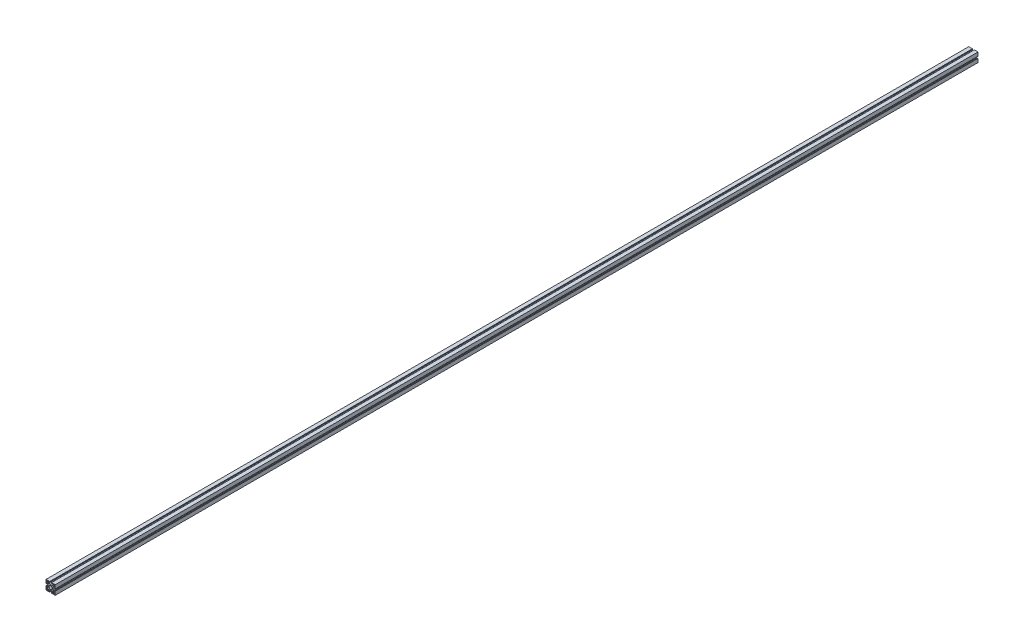
from build123d import *

# Parameters (mm, degrees)
CROQUIS1_R              = 6.85
SALIENTE_EXTRUIR1_DEPTH = 4000


with BuildPart() as part:
    # Croquis1 → Saliente-Extruir1 (new body)
    with BuildSketch(Plane.XY):
        with BuildLine():
            Line((-20, -20), (-4.095, -20))
            Line((-4.095, -20), (-4.095, -19.49))
            ThreePointArc((-4.095, -19.49), (-4.182867966, -19.277867966), (-4.395, -19.19))
            Line((-4.395, -19.19), (-4.730448424, -19.19))
            Line((-4.730448424, -19.19), (-4.730448424, -18.19))
            Line((-4.730448424, -18.19), (-4.395, -18.19))
            ThreePointArc((-4.395, -18.19), (-4.182867966, -18.102132034), (-4.095, -17.89))
            Line((-4.095, -17.89), (-4.095, -16.49))
            ThreePointArc((-4.095, -16.49), (-4.182867966, -16.277867966), (-4.395, -16.19))
            Line((-4.395, -16.19), (-6.206379539, -16.19))
            ThreePointArc((-6.206379539, -16.19), (-6.55993293, -16.336446609), (-6.706379539, -16.69))
            Line((-6.706379539, -16.69), (-6.706379539, -18.19))
            Line((-6.706379539, -18.19), (-10.5, -18.19))
            ThreePointArc((-10.5, -18.19), (-10.853553391, -18.043553391), (-11, -17.69))
            Line((-11, -17.69), (-11, -15))
            ThreePointArc((-11, -15), (-9.828427125, -12.171572875), (-7, -11))
            Line((-7, -11), (7, -11))
            ThreePointArc((7, -11), (9.828427125, -12.171572875), (11, -15))
            Line((11, -15), (11, -17.69))
            ThreePointArc((11, -17.69), (10.853553391, -18.043553391), (10.5, -18.19))
            Line((10.5, -18.19), (6.706379539, -18.19))
            Line((6.706379539, -18.19), (6.706379539, -16.69))
            ThreePointArc((6.706379539, -16.69), (6.55993293, -16.336446609), (6.206379539, -16.19))
            Line((6.206379539, -16.19), (4.395, -16.19))
            ThreePointArc((4.395, -16.19), (4.182867966, -16.277867966), (4.095, -16.49))
            Line((4.095, -16.49), (4.095, -17.89))
            ThreePointArc((4.095, -17.89), (4.182867966, -18.102132034), (4.395, -18.19))
            Line((4.395, -18.19), (4.730448424, -18.19))
            Line((4.730448424, -18.19), (4.730448424, -19.19))
            Line((4.730448424, -19.19), (4.395, -19.19))
            ThreePointArc((4.395, -19.19), (4.182867966, -19.277867966), (4.095, -19.49))
            Line((4.095, -19.49), (4.095, -20))
            Line((4.095, -20), (20, -20))
            Line((20, -20), (20, -4.095))
            Line((20, -4.095), (19.49, -4.095))
            ThreePointArc((19.49, -4.095), (19.277867966, -4.182867966), (19.19, -4.395))
            Line((19.19, -4.395), (19.19, -4.730448424))
            Line((19.19, -4.730448424), (18.19, -4.730448424))
            Line((18.19, -4.730448424), (18.19, -4.395))
            ThreePointArc((18.19, -4.395), (18.102132034, -4.182867966), (17.89, -4.095))
            Line((17.89, -4.095), (16.49, -4.095))
            ThreePointArc((16.49, -4.095), (16.277867966, -4.182867966), (16.19, -4.395))
            Line((16.19, -4.395), (16.19, -6.206379539))
            ThreePointArc((16.19, -6.206379539), (16.336446609, -6.55993293), (16.69, -6.706379539))
            Line((16.69, -6.706379539), (18.19, -6.706379539))
            Line((18.19, -6.706379539), (18.19, -10.5))
            ThreePointArc((18.19, -10.5), (18.043553391, -10.853553391), (17.69, -11))
            Line((17.69, -11), (15, -11))
            ThreePointArc((15, -11), (12.171572875, -9.828427125), (11, -7))
            Line((11, -7), (11, 7))
            ThreePointArc((11, 7), (12.171572875, 9.828427125), (15, 11))
            Line((15, 11), (17.69, 11))
            ThreePointArc((17.69, 11), (18.043553391, 10.853553391), (18.19, 10.5))
            Line((18.19, 10.5), (18.19, 6.706379539))
            Line((18.19, 6.706379539), (16.69, 6.706379539))
            ThreePointArc((16.69, 6.706379539), (16.336446609, 6.55993293), (16.19, 6.206379539))
            Line((16.19, 6.206379539), (16.19, 4.395))
            ThreePointArc((16.19, 4.395), (16.277867966, 4.182867966), (16.49, 4.095))
            Line((16.49, 4.095), (17.89, 4.095))
            ThreePointArc((17.89, 4.095), (18.102132034, 4.182867966), (18.19, 4.395))
            Line((18.19, 4.395), (18.19, 4.730448424))
            Line((18.19, 4.730448424), (19.19, 4.730448424))
            Line((19.19, 4.730448424), (19.19, 4.395))
            ThreePointArc((19.19, 4.395), (19.277867966, 4.182867966), (19.49, 4.095))
            Line((19.49, 4.095), (20, 4.095))
            Line((20, 4.095), (20, 20))
            Line((20, 20), (4.095, 20))
            Line((4.095, 20), (4.095, 19.49))
            ThreePointArc((4.095, 19.49), (4.182867966, 19.277867966), (4.395, 19.19))
            Line((4.395, 19.19), (4.730448424, 19.19))
            Line((4.730448424, 19.19), (4.730448424, 18.19))
            Line((4.730448424, 18.19), (4.395, 18.19))
            ThreePointArc((4.395, 18.19), (4.182867966, 18.102132034), (4.095, 17.89))
            Line((4.095, 17.89), (4.095, 16.49))
            ThreePointArc((4.095, 16.49), (4.182867966, 16.277867966), (4.395, 16.19))
            Line((4.395, 16.19), (6.206379539, 16.19))
            ThreePointArc((6.206379539, 16.19), (6.55993293, 16.336446609), (6.706379539, 16.69))
            Line((6.706379539, 16.69), (6.706379539, 18.19))
            Line((6.706379539, 18.19), (10.5, 18.19))
            ThreePointArc((10.5, 18.19), (10.853553391, 18.043553391), (11, 17.69))
            Line((11, 17.69), (11, 15))
            ThreePointArc((11, 15), (9.828427125, 12.171572875), (7, 11))
            Line((7, 11), (-7, 11))
            ThreePointArc((-7, 11), (-9.828427125, 12.171572875), (-11, 15))
            Line((-11, 15), (-11, 17.69))
            ThreePointArc((-11, 17.69), (-10.853553391, 18.043553391), (-10.5, 18.19))
            Line((-10.5, 18.19), (-6.706379539, 18.19))
            Line((-6.706379539, 18.19), (-6.706379539, 16.69))
            ThreePointArc((-6.706379539, 16.69), (-6.55993293, 16.336446609), (-6.206379539, 16.19))
            Line((-6.206379539, 16.19), (-4.395, 16.19))
            ThreePointArc((-4.395, 16.19), (-4.182867966, 16.277867966), (-4.095, 16.49))
            Line((-4.095, 16.49), (-4.095, 17.89))
            ThreePointArc((-4.095, 17.89), (-4.182867966, 18.102132034), (-4.395, 18.19))
            Line((-4.395, 18.19), (-4.730448424, 18.19))
            Line((-4.730448424, 18.19), (-4.730448424, 19.19))
            Line((-4.730448424, 19.19), (-4.395, 19.19))
            ThreePointArc((-4.395, 19.19), (-4.182867966, 19.277867966), (-4.095, 19.49))
            Line((-4.095, 19.49), (-4.095, 20))
            Line((-4.095, 20), (-20, 20))
            Line((-20, 20), (-20, 4.095))
            Line((-20, 4.095), (-19.49, 4.095))
            ThreePointArc((-19.49, 4.095), (-19.277867966, 4.182867966), (-19.19, 4.395))
            Line((-19.19, 4.395), (-19.19, 4.730448424))
            Line((-19.19, 4.730448424), (-18.19, 4.730448424))
            Line((-18.19, 4.730448424), (-18.19, 4.395))
            ThreePointArc((-18.19, 4.395), (-18.102132034, 4.182867966), (-17.89, 4.095))
            Line((-17.89, 4.095), (-16.49, 4.095))
            ThreePointArc((-16.49, 4.095), (-16.277867966, 4.182867966), (-16.19, 4.395))
            Line((-16.19, 4.395), (-16.19, 6.206379539))
            ThreePointArc((-16.19, 6.206379539), (-16.336446609, 6.55993293), (-16.69, 6.706379539))
            Line((-16.69, 6.706379539), (-18.19, 6.706379539))
            Line((-18.19, 6.706379539), (-18.19, 10.5))
            ThreePointArc((-18.19, 10.5), (-18.043553391, 10.853553391), (-17.69, 11))
            Line((-17.69, 11), (-15, 11))
            ThreePointArc((-15, 11), (-12.171572875, 9.828427125), (-11, 7))
            Line((-11, 7), (-11, -7))
            ThreePointArc((-11, -7), (-12.171572875, -9.828427125), (-15, -11))
            Line((-15, -11), (-17.69, -11))
            ThreePointArc((-17.69, -11), (-18.043553391, -10.853553391), (-18.19, -10.5))
            Line((-18.19, -10.5), (-18.19, -6.706379539))
            Line((-18.19, -6.706379539), (-16.69, -6.706379539))
            ThreePointArc((-16.69, -6.706379539), (-16.336446609, -6.55993293), (-16.19, -6.206379539))
            Line((-16.19, -6.206379539), (-16.19, -4.395))
            ThreePointArc((-16.19, -4.395), (-16.277867966, -4.182867966), (-16.49, -4.095))
            Line((-16.49, -4.095), (-17.89, -4.095))
            ThreePointArc((-17.89, -4.095), (-18.102132034, -4.182867966), (-18.19, -4.395))
            Line((-18.19, -4.395), (-18.19, -4.730448424))
            Line((-18.19, -4.730448424), (-19.19, -4.730448424))
            Line((-19.19, -4.730448424), (-19.19, -4.395))
            ThreePointArc((-19.19, -4.395), (-19.277867966, -4.182867966), (-19.49, -4.095))
            Line((-19.49, -4.095), (-20, -4.095))
            Line((-20, -4.095), (-20, -20))
        make_face()
        Circle(CROQUIS1_R, mode=Mode.SUBTRACT)
        with BuildLine():
            Line((-14.109034097, -13.422690717), (-13.737612474, -13.051269094))
            Line((-13.737612474, -13.051269094), (-13.051269094, -13.737612474))
            Line((-13.051269094, -13.737612474), (-13.422690717, -14.109034097))
            ThreePointArc((-13.422690717, -14.109034097), (-13, -15.5), (-13.422690717, -16.890965903))
            Line((-13.422690717, -16.890965903), (-13.051269094, -17.262387526))
            Line((-13.051269094, -17.262387526), (-13.737612474, -17.948730906))
            Line((-13.737612474, -17.948730906), (-14.109034097, -17.577309283))
            ThreePointArc((-14.109034097, -17.577309283), (-15.5, -18), (-16.890965903, -17.577309283))
            Line((-16.890965903, -17.577309283), (-17.262387526, -17.948730906))
            Line((-17.262387526, -17.948730906), (-17.948730906, -17.262387526))
            Line((-17.948730906, -17.262387526), (-17.577309283, -16.890965903))
            ThreePointArc((-17.577309283, -16.890965903), (-18, -15.5), (-17.577309283, -14.109034097))
            Line((-17.577309283, -14.109034097), (-17.948730906, -13.737612474))
            Line((-17.948730906, -13.737612474), (-17.262387526, -13.051269094))
            Line((-17.262387526, -13.051269094), (-16.890965903, -13.422690717))
            ThreePointArc((-16.890965903, -13.422690717), (-15.5, -13), (-14.109034097, -13.422690717))
        make_face(mode=Mode.SUBTRACT)
        with BuildLine():
            Line((-14.109034097, 13.422690717), (-13.737612474, 13.051269094))
            Line((-13.737612474, 13.051269094), (-13.051269094, 13.737612474))
            Line((-13.051269094, 13.737612474), (-13.422690717, 14.109034097))
            ThreePointArc((-13.422690717, 14.109034097), (-13, 15.5), (-13.422690717, 16.890965903))
            Line((-13.422690717, 16.890965903), (-13.051269094, 17.262387526))
            Line((-13.051269094, 17.262387526), (-13.737612474, 17.948730906))
            Line((-13.737612474, 17.948730906), (-14.109034097, 17.577309283))
            ThreePointArc((-14.109034097, 17.577309283), (-15.5, 18), (-16.890965903, 17.577309283))
            Line((-16.890965903, 17.577309283), (-17.262387526, 17.948730906))
            Line((-17.262387526, 17.948730906), (-17.948730906, 17.262387526))
            Line((-17.948730906, 17.262387526), (-17.577309283, 16.890965903))
            ThreePointArc((-17.577309283, 16.890965903), (-18, 15.5), (-17.577309283, 14.109034097))
            Line((-17.577309283, 14.109034097), (-17.948730906, 13.737612474))
            Line((-17.948730906, 13.737612474), (-17.262387526, 13.051269094))
            Line((-17.262387526, 13.051269094), (-16.890965903, 13.422690717))
            ThreePointArc((-16.890965903, 13.422690717), (-15.5, 13), (-14.109034097, 13.422690717))
        make_face(mode=Mode.SUBTRACT)
        with BuildLine():
            Line((13.422690717, 14.109034097), (13.051269094, 13.737612474))
            Line((13.051269094, 13.737612474), (13.737612474, 13.051269094))
            Line((13.737612474, 13.051269094), (14.109034097, 13.422690717))
            ThreePointArc((14.109034097, 13.422690717), (15.5, 13), (16.890965903, 13.422690717))
            Line((16.890965903, 13.422690717), (17.262387526, 13.051269094))
            Line((17.262387526, 13.051269094), (17.948730906, 13.737612474))
            Line((17.948730906, 13.737612474), (17.577309283, 14.109034097))
            ThreePointArc((17.577309283, 14.109034097), (18, 15.5), (17.577309283, 16.890965903))
            Line((17.577309283, 16.890965903), (17.948730906, 17.262387526))
            Line((17.948730906, 17.262387526), (17.262387526, 17.948730906))
            Line((17.262387526, 17.948730906), (16.890965903, 17.577309283))
            ThreePointArc((16.890965903, 17.577309283), (15.5, 18), (14.109034097, 17.577309283))
            Line((14.109034097, 17.577309283), (13.737612474, 17.948730906))
            Line((13.737612474, 17.948730906), (13.051269094, 17.262387526))
            Line((13.051269094, 17.262387526), (13.422690717, 16.890965903))
            ThreePointArc((13.422690717, 16.890965903), (13, 15.5), (13.422690717, 14.109034097))
        make_face(mode=Mode.SUBTRACT)
        with BuildLine():
            Line((14.109034097, -13.422690717), (13.737612474, -13.051269094))
            Line((13.737612474, -13.051269094), (13.051269094, -13.737612474))
            Line((13.051269094, -13.737612474), (13.422690717, -14.109034097))
            ThreePointArc((13.422690717, -14.109034097), (13, -15.5), (13.422690717, -16.890965903))
            Line((13.422690717, -16.890965903), (13.051269094, -17.262387526))
            Line((13.051269094, -17.262387526), (13.737612474, -17.948730906))
            Line((13.737612474, -17.948730906), (14.109034097, -17.577309283))
            ThreePointArc((14.109034097, -17.577309283), (15.5, -18), (16.890965903, -17.577309283))
            Line((16.890965903, -17.577309283), (17.262387526, -17.948730906))
            Line((17.262387526, -17.948730906), (17.948730906, -17.262387526))
            Line((17.948730906, -17.262387526), (17.577309283, -16.890965903))
            ThreePointArc((17.577309283, -16.890965903), (18, -15.5), (17.577309283, -14.109034097))
            Line((17.577309283, -14.109034097), (17.948730906, -13.737612474))
            Line((17.948730906, -13.737612474), (17.262387526, -13.051269094))
            Line((17.262387526, -13.051269094), (16.890965903, -13.422690717))
            ThreePointArc((16.890965903, -13.422690717), (15.5, -13), (14.109034097, -13.422690717))
        make_face(mode=Mode.SUBTRACT)
    extrude(amount=SALIENTE_EXTRUIR1_DEPTH)


solid = part.part
